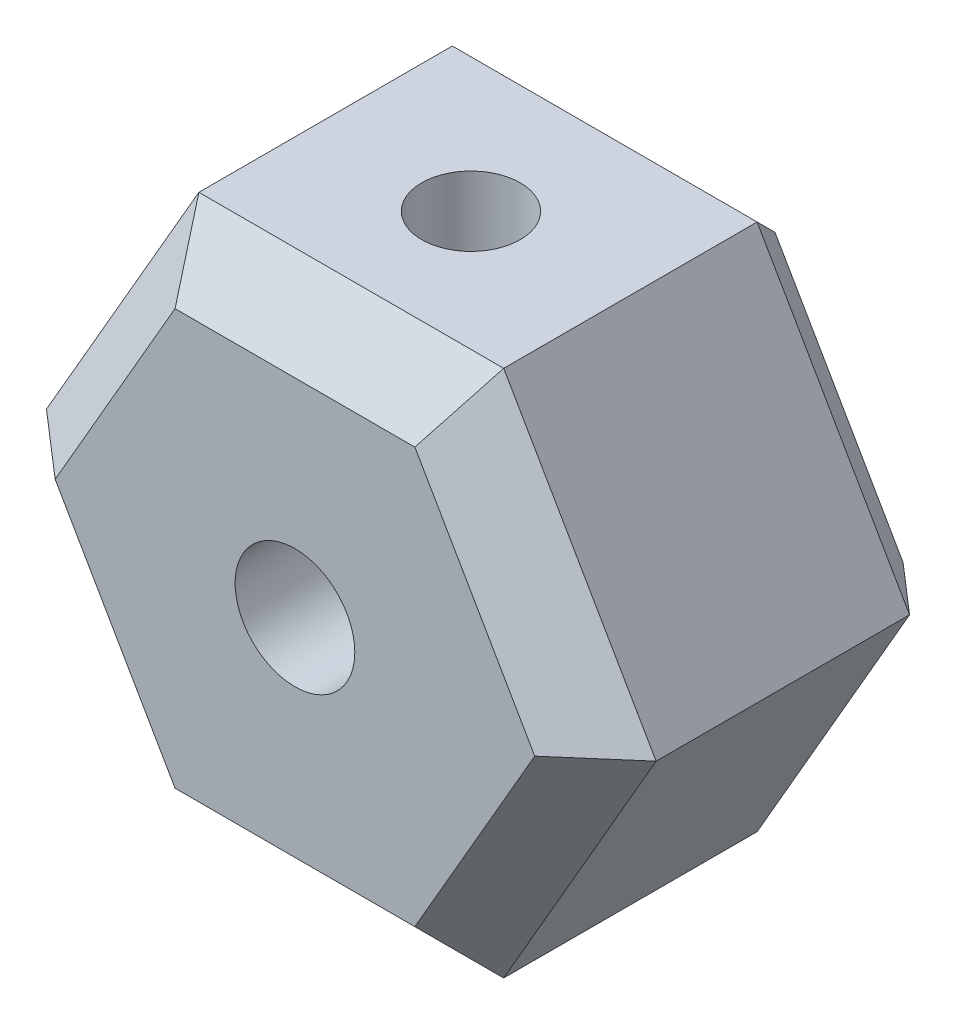
from build123d import *

# Parameters (mm, degrees)
SKETCH1_R           = 1.7
BOSS_EXTRUDE1_DEPTH = 10
SKETCH2_R           = 1.4
CUT_EXTRUDE1_DEPTH  = 16
CHAMFER1_SIZE       = 1.6
CHAMFER2_SIZE       = 1.2


with BuildPart() as part:
    # Sketch1 → Boss-Extrude1 (new body)
    with BuildSketch(Plane.XY):
        Polygon((8.660254038, 0), (4.330127019, 7.5), (-4.330127019, 7.5), (-8.660254038, 0), (-4.330127019, -7.5), (4.330127019, -7.5), align=None)
        Circle(SKETCH1_R, mode=Mode.SUBTRACT)
    extrude(amount=BOSS_EXTRUDE1_DEPTH)

    # Sketch2 → Cut-Extrude1 (cut, through all)
    with BuildSketch(Plane.XZ.offset(7.5)):
        with Locations((0, 5)):
            Circle(SKETCH2_R)
    extrude(amount=-CUT_EXTRUDE1_DEPTH, mode=Mode.SUBTRACT)

    # Chamfer1
    chamfer1_edges = [part.edges().sort_by_distance(p)[0] for p in [
        (0, 7.5, 10),
        (-6.495190528, 3.75, 10),
        (-6.495190528, -3.75, 10),
        (0, -7.5, 10),
        (6.495190528, -3.75, 10),
        (6.495190528, 3.75, 10),
    ]]
    chamfer(chamfer1_edges, length=CHAMFER1_SIZE)

    # Chamfer2
    chamfer2_edges = [part.edges().sort_by_distance(p)[0] for p in [
        (0, -7.5, 0),
        (-6.495190528, -3.75, 0),
        (-6.495190528, 3.75, 0),
        (0, 7.5, 0),
        (6.495190528, 3.75, 0),
        (6.495190528, -3.75, 0),
    ]]
    chamfer(chamfer2_edges, length=CHAMFER2_SIZE)


solid = part.part
